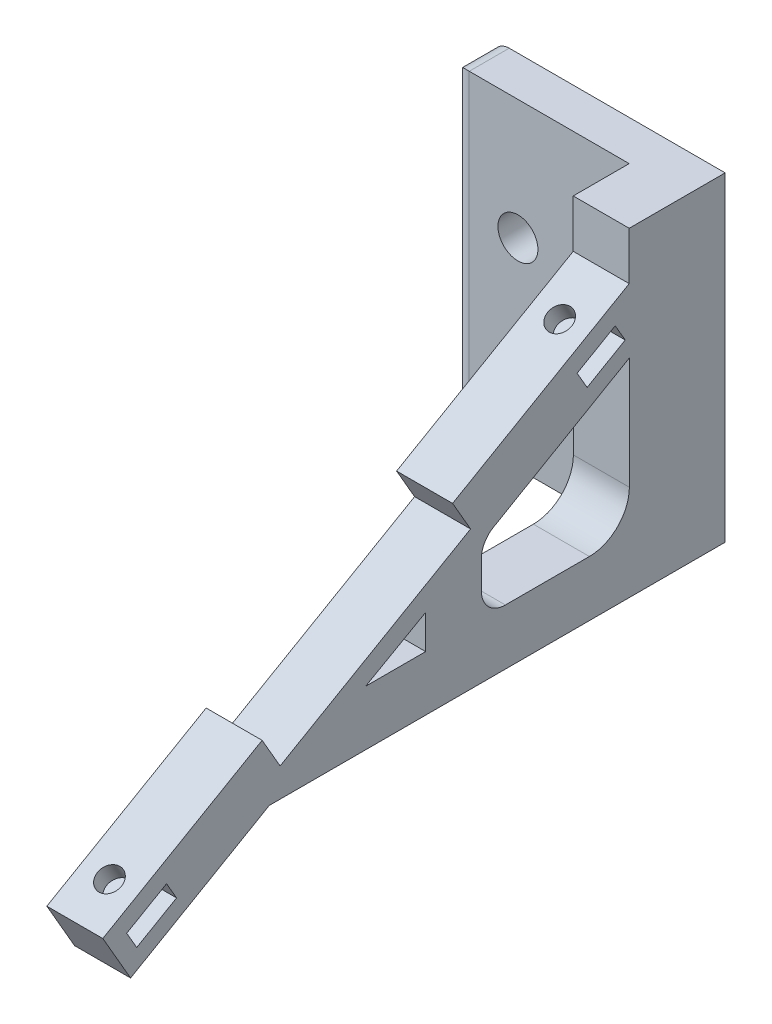
from build123d import *

# Parameters (mm, degrees)
BOSS_EXTRUDE1_DEPTH = 7
SKETCH2_W           = 29
SKETCH2_H           = 40
SKETCH2_R           = 2.5
BOSS_EXTRUDE2_DEPTH = 5
FILLET1_R           = 2
SKETCH3_R           = 1.5
CUT_EXTRUDE1_DEPTH  = 7.5


with BuildPart() as part:
    # Sketch1 → Boss-Extrude1 (new body)
    with BuildSketch(Plane(origin=(0, 0, 0), x_dir=(0, 0, -1), z_dir=(1, 0, 0))):
        Polygon((0, 0), (0, 40), (-7, 40), (-7, 34), (-29.083647797, 21.25), (-26.833647797, 17.352885683), (-50.649346401, 3.602885683), (-52.899346401, 7.5), (-72.817930688, -4), (-69.345498823, -10.014428415), (-52, 0), align=None)
        Polygon((-69.828328815, -4.926142338), (-64.848682743, -2.051142338), (-63.598682743, -4.216205848), (-68.578328815, -7.091205848), align=None, mode=Mode.SUBTRACT)
        Polygon((-39.949930688, 6.884), (-32.449930688, 11.134), (-32.449930688, 6.884), align=None, mode=Mode.SUBTRACT)
        with BuildLine():
            Line((-6.98, 25.947), (-6.98, 11.947))
            ThreePointArc((-6.98, 11.947), (-8.444466094, 8.411466094), (-11.98, 6.947))
            Line((-11.98, 6.947), (-22.48, 6.947))
            ThreePointArc((-22.48, 6.947), (-24.601320344, 7.825679656), (-25.48, 9.947))
            Line((-25.48, 9.947), (-25.48, 13.505607896))
            ThreePointArc((-25.48, 13.505607896), (-25.078135635, 15.007043949), (-23.98, 16.107))
            Line((-23.98, 16.107), (-6.98, 25.947))
        make_face(mode=Mode.SUBTRACT)
        Polygon((-13.512490144, 27.556681889), (-8.752389988, 30.311939862), (-7.5, 28.148257973), (-12.260100157, 25.393), align=None, mode=Mode.SUBTRACT)
    extrude(amount=-BOSS_EXTRUDE1_DEPTH)

    # Sketch2 → Boss-Extrude2 (add)
    with BuildSketch(Plane(origin=(0, 0, 0), x_dir=(-1, 0, 0), z_dir=(0, 0, -1))):
        with Locations((14.5, 20)):
            Rectangle(SKETCH2_W, SKETCH2_H)
        with Locations((20.9125, 25)):
            Circle(SKETCH2_R, mode=Mode.SUBTRACT)
        with Locations((20.9125, 5)):
            Circle(SKETCH2_R, mode=Mode.SUBTRACT)
    extrude(amount=BOSS_EXTRUDE2_DEPTH)

    # Fillet1
    fillet1_edges = [part.edges().sort_by_distance(p)[0] for p in [
        (-29, 20, 0),
        (-29, 0, -2.5),
        (-29, 40, -2.5),
    ]]
    fillet(fillet1_edges, radius=FILLET1_R)

    # Sketch3 → Cut-Extrude1 (cut)
    with BuildSketch(Plane(origin=(0, 28.531088913, 16.472431864), x_dir=(1, 0, 0), z_dir=(0, 0.866025404, 0.5))):
        with Locations((-3.5, 4.937822174)):
            Circle(SKETCH3_R)
        with Locations((-3.5, -60.062177826)):
            Circle(SKETCH3_R)
    extrude(amount=-CUT_EXTRUDE1_DEPTH, mode=Mode.SUBTRACT)


solid = part.part
